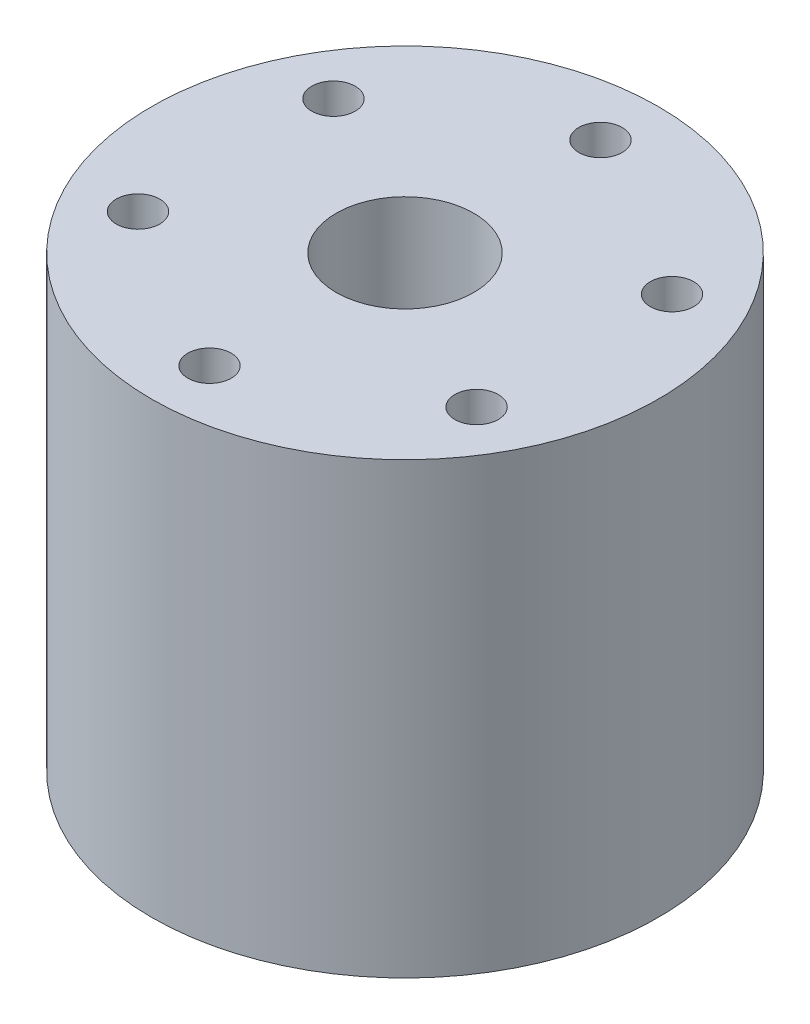
from build123d import *

# Parameters (mm, degrees)
SKETCH_1_R      = 17.5
SKETCH_1_R_2    = 1.5
SKETCH_1_R_3    = 4.75
EXTRUDE_1_DEPTH = 31


with BuildPart() as part:
    # 草图1 → 凸台-拉伸1 (new body)
    with BuildSketch(Plane(origin=(0, 0, 0), x_dir=(1, 0, 0), z_dir=(0, 1, 0))):
        Circle(SKETCH_1_R)
        with Locations((11.691342951, 6.75)):
            Circle(SKETCH_1_R_2, mode=Mode.SUBTRACT)
        Circle(SKETCH_1_R_3, mode=Mode.SUBTRACT)
        with Locations((0, 13.5)):
            Circle(SKETCH_1_R_2, mode=Mode.SUBTRACT)
        with Locations((11.691342951, -6.75)):
            Circle(SKETCH_1_R_2, mode=Mode.SUBTRACT)
        with Locations((0, -13.5)):
            Circle(SKETCH_1_R_2, mode=Mode.SUBTRACT)
        with Locations((-11.691342951, -6.75)):
            Circle(SKETCH_1_R_2, mode=Mode.SUBTRACT)
        with Locations((-11.691342951, 6.75)):
            Circle(SKETCH_1_R_2, mode=Mode.SUBTRACT)
    extrude(amount=EXTRUDE_1_DEPTH)


solid = part.part
